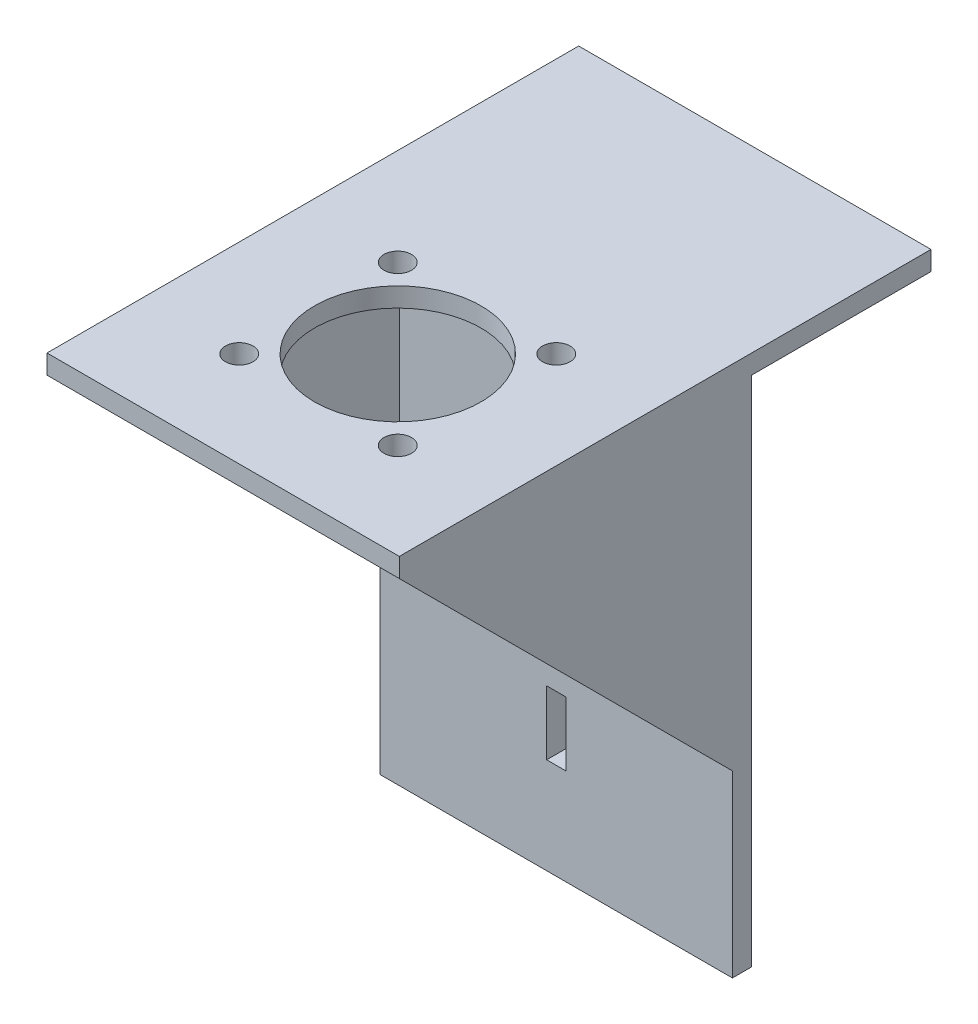
from build123d import *

# Parameters (mm, degrees)
SKETCH1_W           = 55
SKETCH1_H           = 80
SKETCH1_R           = 13
SKETCH1_R_2         = 2.15
BOSS_EXTRUDE2_DEPTH = 3
SKETCH2_W           = 55
SKETCH2_H           = 3
BOSS_EXTRUDE3_DEPTH = 80
SKETCH3_W           = 3
SKETCH3_H           = 10
CUT_EXTRUDE1_DEPTH  = 80
SKETCH4_W           = 55
SKETCH4_H           = 25
BOSS_EXTRUDE4_DEPTH = 3
SKETCH5_W           = 55
SKETCH5_H           = 3
CUT_EXTRUDE2_DEPTH  = 22
BOSS_EXTRUDE5_DEPTH = 3
BOSS_EXTRUDE6_DEPTH = 3


with BuildPart() as part:
    # Sketch1 → Boss-Extrude2 (new body)
    with BuildSketch(Plane(origin=(0, 0, 0), x_dir=(1, 0, 0), z_dir=(0, 1, 0))):
        Rectangle(SKETCH1_W, SKETCH1_H)
        with Locations((0, -12.743931666)):
            Circle(SKETCH1_R, mode=Mode.SUBTRACT)
        with Locations((12.374368671, -0.369562995)):
            Circle(SKETCH1_R_2, mode=Mode.SUBTRACT)
        with Locations((12.374368671, -25.118300337)):
            Circle(SKETCH1_R_2, mode=Mode.SUBTRACT)
        with Locations((-12.374368671, -25.118300337)):
            Circle(SKETCH1_R_2, mode=Mode.SUBTRACT)
        with Locations((-12.374368671, -0.369562995)):
            Circle(SKETCH1_R_2, mode=Mode.SUBTRACT)
    extrude(amount=BOSS_EXTRUDE2_DEPTH)

    # Sketch2 → Boss-Extrude3 (add)
    with BuildSketch(Plane.XZ):
        with Locations((0, -13.5)):
            Rectangle(SKETCH2_W, SKETCH2_H)
    extrude(amount=BOSS_EXTRUDE3_DEPTH)

    # Sketch3 → Cut-Extrude1 (cut)
    with BuildSketch(Plane(origin=(0, 0, -15), x_dir=(-1, 0, 0), z_dir=(0, 0, -1))):
        with Locations((0, -60)):
            Rectangle(SKETCH3_W, SKETCH3_H)
    extrude(amount=-CUT_EXTRUDE1_DEPTH, mode=Mode.SUBTRACT)

    # Sketch4 → Boss-Extrude4 (add)
    with BuildSketch(Plane(origin=(0, 0, -40), x_dir=(-1, 0, 0), z_dir=(0, 0, -1))):
        with Locations((0, -9.5)):
            Rectangle(SKETCH4_W, SKETCH4_H)
    extrude(amount=BOSS_EXTRUDE4_DEPTH)

    # Sketch5 → Cut-Extrude2 (cut)
    with BuildSketch(Plane.XZ.offset(22)):
        with Locations((0, -41.5)):
            Rectangle(SKETCH5_W, SKETCH5_H)
    extrude(amount=-CUT_EXTRUDE2_DEPTH, mode=Mode.SUBTRACT)

    # Sketch6 → Boss-Extrude5 (add)
    with BuildSketch(Plane(origin=(27.5, 0, 0), x_dir=(0, 0, -1), z_dir=(1, 0, 0))):
        Polygon((-40, 0), (12, 0), (12, -52), align=None)
    extrude(amount=-BOSS_EXTRUDE5_DEPTH)

    # Sketch7 → Boss-Extrude6 (add)
    with BuildSketch(Plane.ZY.offset(27.5)):
        Polygon((-12, 0), (40, 0), (-12, -52), align=None)
    extrude(amount=-BOSS_EXTRUDE6_DEPTH)


solid = part.part
